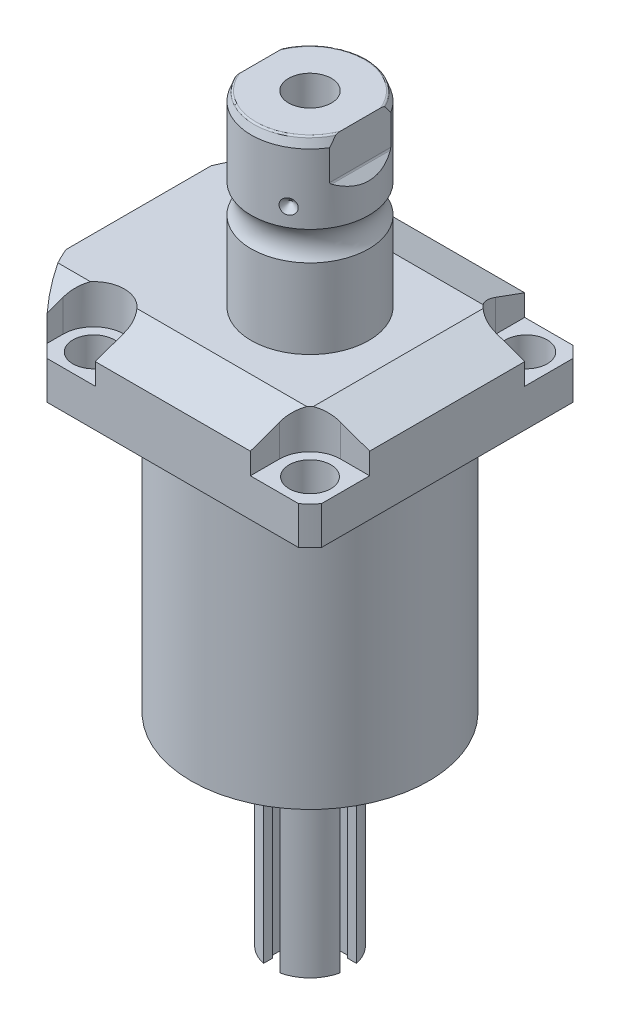
from build123d import *

# Parameters (mm, degrees)
SKETCH1_W                   = 88.9
SKETCH1_H                   = 99.9998
EXTRUDE1_DEPTH              = 113.919
SKETCH2_OUTSIDE_W           = 137.146
SKETCH2_OUTSIDE_H           = 126.046
SKETCH2_OUTSIDE_R           = 60.325
CUT_EXTRUDE1_DEPTH          = 114.919
SKETCH3_W                   = 38.1
SKETCH3_H                   = 88.9
FILLET1_R                   = 0.381
CUT_EXTRUDE2_DEPTH          = 12.7
CUT_EXTRUDE9_START          = -56.5498
CUT_EXTRUDE9_DEPTH          = 101.9998
CUT_EXTRUDE7_DEPTH          = 45.45
CUT_EXTRUDE7_DEPTH_BACK     = 45.45
SKETCH10_R                  = 1.1811
SKETCH11_R                  = 1.1811
CUT_EXTRUDE8_DEPTH          = 53.34
SKETCH17_W                  = 6.7437
SKETCH17_H                  = 12.319
HOLE1_AT_2_COUNT            = 2
HOLE1_AT_2_PITCH            = 70.104
HOLE1_AT_3_COUNT            = 2
HOLE1_AT_3_PITCH            = 99.142027577
HOLE1_AT_4_COUNT            = 2
HOLE1_AT_4_PITCH            = 70.104
CHAMFER1_SIZE               = 0.635
FILLET2_R                   = 0.635
CIRPATTERN1_COUNT           = 3
SKETCH24_R                  = 1.7272
CUT_EXTRUDE10_DEPTH         = 2.54
SKETCH25_R                  = 2.7051
EXTRUDE2_DEPTH              = 2.9464
CUT_EXTRUDE11_DEPTH         = 6.477
SKETCH32_W                  = 6.985
SKETCH32_H                  = 54.864
CUT_EXTRUDE12_DEPTH         = 3.302
CUT_EXTRUDE13_DEPTH         = 2.032
CIRPATTERN2_COUNT           = 2
CIRPATTERN2_ANGLE           = 90
CIRPATTERN2_COPY_1_DEPTH    = 6.477
CIRPATTERN2_COPY_2_SKETCH_W = 6.985
CIRPATTERN2_COPY_2_SKETCH_H = 54.864
CIRPATTERN2_COPY_2_DEPTH    = 3.302


with BuildPart() as part:
    # Sketch1 → Extrude1 (new body)
    with BuildSketch(Plane.ZX):
        with Locations((0, -5.5499)):
            Rectangle(SKETCH1_W, SKETCH1_H)
    extrude(amount=EXTRUDE1_DEPTH)

    # Sketch2 outside → Cut-Extrude1 (cut, through all)
    with BuildSketch(Plane.XZ):
        with Locations((-5.55, 0)):
            Rectangle(SKETCH2_OUTSIDE_W, SKETCH2_OUTSIDE_H)
        Circle(SKETCH2_OUTSIDE_R, mode=Mode.SUBTRACT)
    extrude(amount=-CUT_EXTRUDE1_DEPTH, mode=Mode.SUBTRACT)

    # Sketch3 → Cut-Revolve1 (revolve, cut)
    with BuildSketch(Plane(origin=(0, 0, 0), x_dir=(0, 0, 1), z_dir=(1, 0, 0))):
        with Locations((57.5437, -44.45)):
            Rectangle(SKETCH3_W, SKETCH3_H)
    revolve(axis=Axis((0, 93.345, 0), (0, -1, 0)), mode=Mode.SUBTRACT)

    # Fillet1
    fillet1_edges = [part.edges().sort_by_distance(p)[0] for p in [
        (0, 88.9, -38.4937),
    ]]
    fillet(fillet1_edges, radius=FILLET1_R)

    # Sketch4 → Cut-Extrude2 (cut)
    with BuildSketch(Plane(origin=(0, 113.919, 0), x_dir=(-1, 0, 0), z_dir=(0, 1, 0))):
        with BuildLine():
            Line((-25.1206, -44.45), (-25.1206, -35.052))
            ThreePointArc((-25.1206, -35.052), (-28.029439713, -28.029439713), (-35.052, -25.1206))
            Line((-35.052, -25.1206), (-44.45, -25.1206))
            Line((-44.45, -25.1206), (-44.45, -44.45))
            Line((-44.45, -44.45), (-25.1206, -44.45))
        make_face()
        with BuildLine():
            Line((44.9834, -44.45), (25.1206, -44.45))
            Line((25.1206, -44.45), (25.1206, -35.052))
            ThreePointArc((25.1206, -35.052), (35.052, -25.1206), (44.9834, -35.052))
            Line((44.9834, -35.052), (44.9834, -44.45))
        make_face()
        with BuildLine():
            Line((25.1206, 44.45), (25.1206, 35.052))
            ThreePointArc((25.1206, 35.052), (35.052, 25.1206), (44.9834, 35.052))
            Line((44.9834, 35.052), (44.9834, 44.45))
            Line((44.9834, 44.45), (25.1206, 44.45))
        make_face()
        with BuildLine():
            Line((-35.052, 25.1206), (-44.45, 25.1206))
            Line((-44.45, 25.1206), (-44.45, 44.45))
            Line((-44.45, 44.45), (-25.1206, 44.45))
            Line((-25.1206, 44.45), (-25.1206, 35.052))
            ThreePointArc((-25.1206, 35.052), (-28.029439713, 28.029439713), (-35.052, 25.1206))
        make_face()
    extrude(amount=-CUT_EXTRUDE2_DEPTH, mode=Mode.SUBTRACT)

    # Sketch5 → Cut-Extrude9 (cut)
    with BuildSketch(Plane(origin=(0, 0, 0), x_dir=(0, 0, -1), z_dir=(1, 0, 0)).offset(CUT_EXTRUDE9_START)):
        Polygon((-28.575, 113.919), (-44.45, 108.140972531), (-44.45, 113.919), align=None)
    cut_extrude9 = extrude(amount=CUT_EXTRUDE9_DEPTH, mode=Mode.SUBTRACT)

    # Mirror1: Cut-Extrude9 across plane
    add(cut_extrude9.mirror(Plane.XY), mode=Mode.SUBTRACT)

    # Sketch9 → Cut-Extrude7 (cut, two sides)
    with BuildSketch(Plane.XY) as cut_extrude7_sk:
        Polygon((28.575, 113.919), (44.45, 108.140972531), (44.45, 113.919), align=None)
    extrude(amount=CUT_EXTRUDE7_DEPTH, mode=Mode.SUBTRACT)
    extrude(cut_extrude7_sk.sketch, amount=-CUT_EXTRUDE7_DEPTH_BACK, mode=Mode.SUBTRACT)

    # Sketch20 → Cut-Revolve4 (revolve, cut)
    with BuildSketch(Plane(origin=(-41.402, 88.9, -18.1102), x_dir=(0, 1, 0), z_dir=(1, 0, 0)), mode=Mode.PRIVATE) as cut_revolve4_sk:
        Polygon((0, 41.9227), (1.4478, 41.9227), (1.4478, 39.4716), (2.4638, 39.4716), (2.4638, 37.465), (13.4366, 37.465), (13.4366, 36.2204), (0, 36.2204), align=None)
    cut_revolve4 = revolve(cut_revolve4_sk.sketch.rotate(Axis((-41.402, 81.620304954, 18.1102), (0, 1, 0)), 180), axis=Axis((-41.402, 81.620304954, 18.1102), (0, 1, 0)), mode=Mode.SUBTRACT)  # turned: the seam where the file's is

    # Mirror10: Cut-Revolve4 across plane
    add(cut_revolve4.mirror(Plane.XY), mode=Mode.SUBTRACT)

    # S2D0007 → Cut-Revolve2 (revolve, cut)
    with BuildSketch(Plane(origin=(-55.5498, 101.9048, 12.9794), x_dir=(0, 1, 0), z_dir=(0, 0, 1)), mode=Mode.PRIVATE) as cut_revolve2_sk:
        Polygon((0, 0), (10.4775, 0), (10.4775, -0.254), (6.1849, -0.254), (5.642306865, -2.8067), (4.9784, -3.470606865), (4.9784, -14.224), (0, -14.224), align=None)
    revolve(cut_revolve2_sk.sketch.rotate(Axis((-40.6146, 101.9048, 12.9794), (-1, 0, 0)), 90), axis=Axis((-40.6146, 101.9048, 12.9794), (-1, 0, 0)), mode=Mode.SUBTRACT)  # turned: the seam where the file's is

    # Sketch13 → Cut-Revolve3 (revolve, cut)
    with BuildSketch(Plane(origin=(-55.5498, 101.9048, -12.9794), x_dir=(0, 1, 0), z_dir=(0, 0, 1)), mode=Mode.PRIVATE) as cut_revolve3_sk:
        Polygon((0, 0), (10.4775, 0), (10.4775, -0.254), (6.1849, -0.254), (5.642306865, -2.8067), (4.9784, -3.470606865), (4.9784, -14.224), (0, -14.224), align=None)
    revolve(cut_revolve3_sk.sketch.rotate(Axis((-40.6146, 101.9048, -12.9794), (-1, 0, 0)), 90), axis=Axis((-40.6146, 101.9048, -12.9794), (-1, 0, 0)), mode=Mode.SUBTRACT)  # turned: the seam where the file's is

    # Sketch15 → Revolve3 (revolve)
    with BuildSketch(Plane(origin=(0, 0, 0), x_dir=(0, -1, 0), z_dir=(1, 0, 0)), mode=Mode.PRIVATE) as revolve3_sk:
        with BuildLine():
            Line((-113.919, 0), (-113.919, 19.05))
            Line((-113.919, 19.05), (-139.64110643, 19.05))
            ThreePointArc((-139.64110643, 19.05), (-144.3482, 17.5006), (-149.05529357, 19.05))
            Line((-149.05529357, 19.05), (-171.6024, 19.05))
            Line((-171.6024, 19.05), (-174.5234, 17.986842946))
            Line((-174.5234, 17.986842946), (-174.5234, 0))
            Line((-174.5234, 0), (-113.919, 0))
        make_face()
    revolve(revolve3_sk.sketch.rotate(Axis((0, 197.63613, 0), (0, -1, 0)), 180), axis=Axis((0, 197.63613, 0), (0, -1, 0)))  # turned: the seam where the file's is

    # Sketch16 → Cut-Extrude8 (cut, symmetric)
    with BuildSketch(Plane(origin=(0, 0, 0), x_dir=(0, -1, 0), z_dir=(0, 0, -1))):
        with BuildLine():
            Line((-174.5234, 19.05), (-158.739169265, 19.05))
            Line((-158.739169265, 19.05), (-161.284584633, 16.504584633))
            ThreePointArc((-161.284584633, 16.504584633), (-161.531795225, 16.339403796), (-161.8234, 16.2814))
            Line((-161.8234, 16.2814), (-174.5234, 16.2814))
            Line((-174.5234, 16.2814), (-174.5234, 19.05))
        make_face()
        with BuildLine():
            Line((-174.5234, -19.05), (-174.5234, -16.2814))
            Line((-174.5234, -16.2814), (-161.8234, -16.2814))
            ThreePointArc((-161.8234, -16.2814), (-161.531795225, -16.339403796), (-161.284584633, -16.504584633))
            Line((-161.284584633, -16.504584633), (-158.739169265, -19.05))
            Line((-158.739169265, -19.05), (-174.5234, -19.05))
        make_face()
    extrude(amount=CUT_EXTRUDE8_DEPTH, both=True, mode=Mode.SUBTRACT)

    # Sketch17 → Hole1 (revolve, cut)
    with BuildSketch(Plane(origin=(35.052, 101.219, -35.052), x_dir=(0, 0, 1), z_dir=(1, 0, 0))):
        with Locations((3.37185, 6.1595)):
            Rectangle(SKETCH17_W, SKETCH17_H)
    hole1 = revolve(axis=Axis((35.052, -8.781, -35.052), (0, 1, 0)), mode=Mode.SUBTRACT)

    # Hole1 at 2: Hole1 ×2
    with Locations(*[(0, 0, i * HOLE1_AT_2_PITCH) for i in range(1, HOLE1_AT_2_COUNT)]):
        add(hole1, mode=Mode.SUBTRACT)

    # Hole1 at 3: Hole1 ×2
    with Locations(*[Vector(-0.707106781, 0, 0.707106781) * (i * HOLE1_AT_3_PITCH) for i in range(1, HOLE1_AT_3_COUNT)]):
        add(hole1, mode=Mode.SUBTRACT)

    # Hole1 at 4: Hole1 ×2
    with Locations(*[(-i * HOLE1_AT_4_PITCH, 0, 0) for i in range(1, HOLE1_AT_4_COUNT)]):
        add(hole1, mode=Mode.SUBTRACT)

    # Chamfer1
    chamfer1_edges = [part.edges().sort_by_distance(p)[0] for p in [
        (-41.402, 91.3638, 19.3548),
        (-41.402, 91.3638, -19.3548),
    ]]
    chamfer(chamfer1_edges, length=CHAMFER1_SIZE)

    # Sketch21 → Cut-Revolve5 (revolve, cut)
    with BuildSketch(Plane.XY, mode=Mode.PRIVATE) as cut_revolve5_sk:
        Polygon((0, 149.1234), (6.9342, 153.289887704), (6.9342, 174.5234), (0, 174.5234), align=None)
    revolve(cut_revolve5_sk.sketch.rotate(Axis((0, 0, 0), (0, 1, 0)), 270), axis=Axis((0, 0, 0), (0, 1, 0)), mode=Mode.SUBTRACT)  # turned: the seam where the file's is

    # Fillet2
    fillet2_edges = [part.edges().sort_by_distance(p)[0] for p in [
        (0, 174.5234, 17.986842946),
        (0, 174.5234, -17.986842946),
    ]]
    fillet(fillet2_edges, radius=FILLET2_R)

    # Sketch22 → Cut-Revolve6 (revolve, cut)
    with BuildSketch(Plane.XY, mode=Mode.PRIVATE) as cut_revolve6_sk:
        Polygon((-19.05, 157.4292), (-16.637, 155.0162), (-19.05, 155.0162), align=None)
    cut_revolve6 = revolve(cut_revolve6_sk.sketch.rotate(Axis((-37.997376206, 155.0162, 0), (1, 0, 0)), 90), axis=Axis((-37.997376206, 155.0162, 0), (1, 0, 0)), mode=Mode.SUBTRACT)  # turned: the seam where the file's is

    # CirPattern1: Cut-Revolve6 ×3 about axis
    cirpattern1_axis = Axis((0, 197.63613, 0), (0, 1, 0))
    for i in range(1, CIRPATTERN1_COUNT):
        add(cut_revolve6.rotate(cirpattern1_axis, i * 360 / CIRPATTERN1_COUNT), mode=Mode.SUBTRACT)

    # Sketch23 → Revolve5 (revolve)
    with BuildSketch(Plane.XY, mode=Mode.PRIVATE) as revolve5_sk:
        Polygon((0, 0), (22.225, 0), (22.225, -2.54), (12.7, -2.54), (12.7, -65.532), (0, -65.532), align=None)
    revolve(revolve5_sk.sketch.rotate(Axis((0, -1000, 0), (0, 1, 0)), 270), axis=Axis((0, -1000, 0), (0, 1, 0)))  # turned: the seam where the file's is

    # Sketch24 → Cut-Extrude10 (cut)
    with BuildSketch(Plane.XZ.offset(2.54)):
        with Locations((19.431, 0)):
            Circle(SKETCH24_R)
        with Locations((16.827739621, 9.7155)):
            Circle(SKETCH24_R)
        with Locations((9.7155, 16.827739621)):
            Circle(SKETCH24_R)
        with Locations((0, 19.431)):
            Circle(SKETCH24_R)
        with Locations(Location((-9.7155, 16.827739621, 0), (0, 0, 270))):  # turned: the seam where the file's is
            Circle(SKETCH24_R)
        with Locations(Location((-16.827739621, 9.7155, 0), (0, 0, 270))):  # turned: the seam where the file's is
            Circle(SKETCH24_R)
        with Locations(Location((-19.431, 0, 0), (0, 0, 270))):  # turned: the seam where the file's is
            Circle(SKETCH24_R)
        with Locations((-16.827739621, -9.7155)):
            Circle(SKETCH24_R)
        with Locations((-9.7155, -16.827739621)):
            Circle(SKETCH24_R)
        with Locations(Location((0, -19.431, 0), (0, 0, 270))):  # turned: the seam where the file's is
            Circle(SKETCH24_R)
        with Locations(Location((9.7155, -16.827739621, 0), (0, 0, 270))):  # turned: the seam where the file's is
            Circle(SKETCH24_R)
        with Locations(Location((16.827739621, -9.7155, 0), (0, 0, 270))):  # turned: the seam where the file's is
            Circle(SKETCH24_R)
    extrude(amount=-CUT_EXTRUDE10_DEPTH, mode=Mode.SUBTRACT)

    # Sketch25 → Extrude2 (add)
    with BuildSketch(Plane.XZ.offset(2.54)):
        with Locations((19.431, 0)):
            Circle(SKETCH25_R)
        with Locations((-9.7155, 16.827739621)):
            Circle(SKETCH25_R)
        with Locations((-9.7155, -16.827739621)):
            Circle(SKETCH25_R)
    extrude(amount=EXTRUDE2_DEPTH)

    # Sketch31 → Cut-Extrude11 (cut)
    with BuildSketch(Plane(origin=(0, -34.036, 12.7), x_dir=(-1, 0, 0), z_dir=(0, 0, 1))):
        with BuildLine():
            Line((-2.6416, -21.083376248), (-2.6416, 31.496))
            Line((-2.6416, 31.496), (2.6416, 31.496))
            Line((2.6416, 31.496), (2.6416, -21.083376248))
            ThreePointArc((2.6416, -21.083376248), (0, -26.8605), (-2.6416, -21.083376248))
        make_face()
    cut_extrude11 = extrude(amount=-CUT_EXTRUDE11_DEPTH, mode=Mode.SUBTRACT)

    # Sketch32 → Cut-Extrude12 (cut)
    with BuildSketch(Plane.XY.offset(6.223)):
        with Locations((0, -38.1)):
            Rectangle(SKETCH32_W, SKETCH32_H)
    cut_extrude12 = extrude(amount=CUT_EXTRUDE12_DEPTH, mode=Mode.SUBTRACT)

    # Mirror11: Cut-Extrude11, Cut-Extrude12 across plane
    add(cut_extrude11.mirror(Plane.XY), mode=Mode.SUBTRACT)
    add(cut_extrude12.mirror(Plane.XY), mode=Mode.SUBTRACT)

    # Sketch35 → Cut-Extrude13 (cut)
    with BuildSketch(Plane.XZ.offset(5.4864)):
        Polygon((19.431, -1.43714029), (20.6756, -0.718570145), (20.6756, 0.718570145), (19.431, 1.43714029), (18.1864, 0.718570145), (18.1864, -0.718570145), align=None)
        Polygon((-9.255302101, 15.46627346), (-8.306336769, 16.545549612), (-8.766534668, 17.907015772), (-10.175697899, 18.189205782), (-11.124663231, 17.10992963), (-10.664465332, 15.748463469), align=None)
        Polygon((-9.7155, -18.264879911), (-8.4709, -17.546309766), (-8.4709, -16.109169476), (-9.7155, -15.390599331), (-10.9601, -16.109169476), (-10.9601, -17.546309766), align=None)
    extrude(amount=-CUT_EXTRUDE13_DEPTH, mode=Mode.SUBTRACT)

    # CirPattern2: Cut-Extrude11, Cut-Extrude12 ×2 about axis
    cirpattern2_axis = Axis((0, 0, 0), (0, -1, 0))
    add([cut_extrude11.rotate(cirpattern2_axis, i * CIRPATTERN2_ANGLE / (CIRPATTERN2_COUNT - 1)) for i in range(1, CIRPATTERN2_COUNT)], mode=Mode.SUBTRACT)
    add([cut_extrude12.rotate(cirpattern2_axis, i * CIRPATTERN2_ANGLE / (CIRPATTERN2_COUNT - 1)) for i in range(1, CIRPATTERN2_COUNT)], mode=Mode.SUBTRACT)

    # CirPattern2 copy 1 sketch → CirPattern2 copy 1 (cut)
    with BuildSketch(Plane(origin=(12.7, -34.036, 0), x_dir=(0, 0, -1), z_dir=(1, 0, 0))):
        with BuildLine():
            Line((-2.6416, 21.083376248), (-2.6416, -31.496))
            Line((-2.6416, -31.496), (2.6416, -31.496))
            Line((2.6416, -31.496), (2.6416, 21.083376248))
            ThreePointArc((2.6416, 21.083376248), (0, 26.8605), (-2.6416, 21.083376248))
        make_face()
    extrude(amount=-CIRPATTERN2_COPY_1_DEPTH, mode=Mode.SUBTRACT)

    # CirPattern2 copy 2 sketch → CirPattern2 copy 2 (cut)
    with BuildSketch(Plane(origin=(6.223, 0, 0), x_dir=(0, 0, 1), z_dir=(1, 0, 0))):
        with Locations((0, 38.1)):
            Rectangle(CIRPATTERN2_COPY_2_SKETCH_W, CIRPATTERN2_COPY_2_SKETCH_H)
    extrude(amount=CIRPATTERN2_COPY_2_DEPTH, mode=Mode.SUBTRACT)


with BuildPart() as body_2:
    # Sketch10 → Revolve4 (revolve)
    with BuildSketch(Plane(origin=(-41.402, 88.9, -18.1102), x_dir=(0, 1, 0), z_dir=(1, 0, 0))):
        with Locations((0.2667, 4.5212)):
            Circle(SKETCH10_R)
    revolve(axis=Axis((-41.402, 87.86749, -18.1102), (0, 1, 0)))


with BuildPart() as body_3:
    # Sketch11 → Revolve2 (revolve)
    with BuildSketch(Plane(origin=(-41.402, 88.9, 18.1102), x_dir=(0, 1, 0), z_dir=(1, 0, 0)), mode=Mode.PRIVATE) as revolve2_sk:
        with Locations((0.2667, 4.5212)):
            Circle(SKETCH11_R)
    revolve(revolve2_sk.sketch.rotate(Axis((-41.402, 87.86749, 18.1102), (0, 1, 0)), 180), axis=Axis((-41.402, 87.86749, 18.1102), (0, 1, 0)))  # turned: the seam where the file's is


solid = Compound([part.part, body_2.part, body_3.part])
